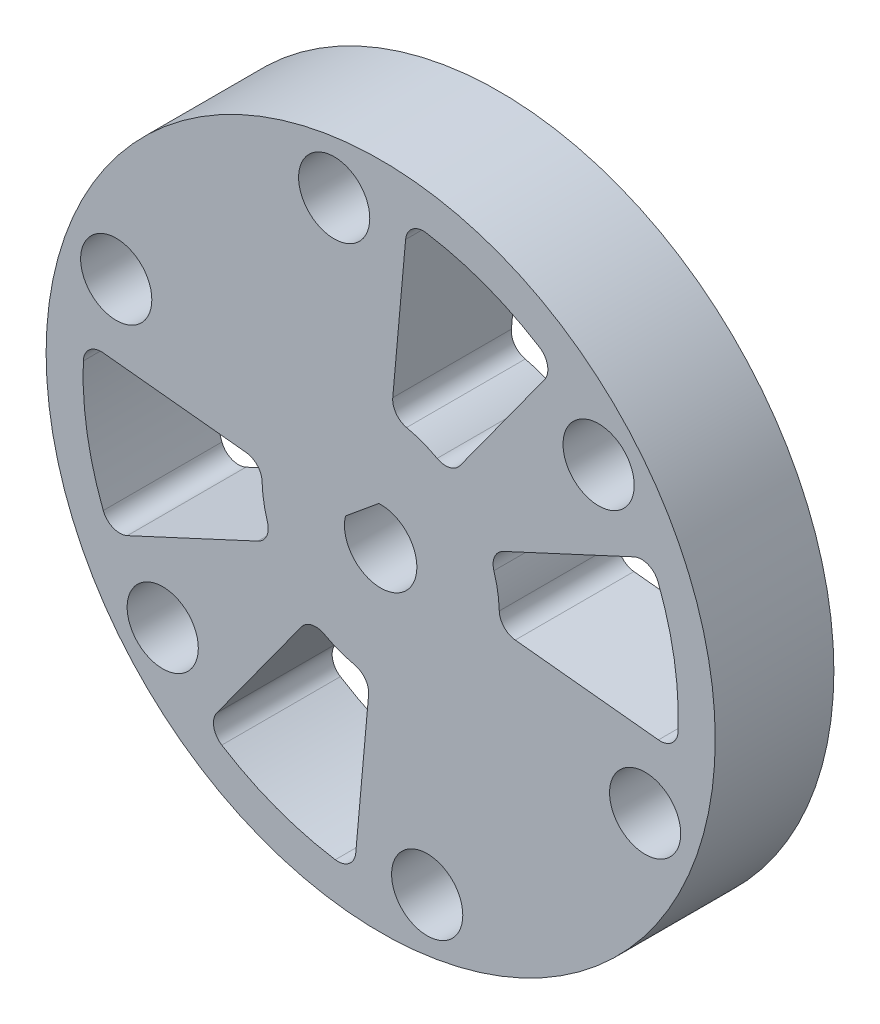
from build123d import *

# Parameters (mm, degrees)
SKETCH1_6_R         = 28.2
SKETCH1_6_R_2       = 3
BOSS_EXTRUDE4_DEPTH = 10
FILLET4_R           = 1.5


with BuildPart() as part:
    # Sketch1_6 → Boss-Extrude4 (new body)
    with BuildSketch(Plane.XY):
        Circle(SKETCH1_6_R)
        with BuildLine():
            ThreePointArc((5.866209712, 8.098616155), (3.505253449, 9.36553246), (0.892648331, 9.960079265))
            Line((0.892648331, 9.960079265), (2.101110424, 23.44397635))
            ThreePointArc((2.101110424, 23.44397635), (2.670485373, 24.491199978), (3.823764506, 24.792550937))
            ThreePointArc((3.823764506, 24.792550937), (8.793169539, 23.494082796), (13.393949598, 21.210701807))
            ThreePointArc((13.393949598, 21.210701807), (14.065968099, 20.226193659), (13.807850128, 19.062475363))
            Line((13.807850128, 19.062475363), (5.866209712, 8.098616155))
        make_face(mode=Mode.SUBTRACT)
        with BuildLine():
            ThreePointArc((-9.946712181, 1.030978557), (-9.863415755, -1.647127697), (-9.072005832, -4.206983501))
            Line((-9.072005832, -4.206983501), (-21.353634297, -9.902373172))
            ThreePointArc((-21.353634297, -9.902373172), (-22.545244036, -9.932891816), (-23.382861189, -9.084798269))
            ThreePointArc((-23.382861189, -9.084798269), (-24.74305731, -4.131933198), (-25.065981396, 0.994149706))
            ThreePointArc((-25.065981396, 0.994149706), (-24.54938158, 2.068388873), (-23.412512987, 2.426711301))
            Line((-23.412512987, 2.426711301), (-9.946712181, 1.030978557))
        make_face(mode=Mode.SUBTRACT)
        with BuildLine():
            ThreePointArc((-5.866209712, -8.098616155), (-3.505253449, -9.36553246), (-0.892648331, -9.960079265))
            Line((-0.892648331, -9.960079265), (-2.101110424, -23.44397635))
            ThreePointArc((-2.101110424, -23.44397635), (-2.670485373, -24.491199978), (-3.823764506, -24.792550937))
            ThreePointArc((-3.823764506, -24.792550937), (-8.793169539, -23.494082796), (-13.393949598, -21.210701807))
            ThreePointArc((-13.393949598, -21.210701807), (-14.065968099, -20.226193659), (-13.807850128, -19.062475363))
            Line((-13.807850128, -19.062475363), (-5.866209712, -8.098616155))
        make_face(mode=Mode.SUBTRACT)
        with BuildLine():
            ThreePointArc((9.946712181, -1.030978557), (9.863415755, 1.647127697), (9.072005832, 4.206983501))
            Line((9.072005832, 4.206983501), (21.353634297, 9.902373172))
            ThreePointArc((21.353634297, 9.902373172), (22.545244036, 9.932891816), (23.382861189, 9.084798269))
            ThreePointArc((23.382861189, 9.084798269), (24.74305731, 4.131933198), (25.065981396, -0.994149706))
            ThreePointArc((25.065981396, -0.994149706), (24.54938158, -2.068388873), (23.412512987, -2.426711301))
            Line((23.412512987, -2.426711301), (9.946712181, -1.030978557))
        make_face(mode=Mode.SUBTRACT)
        with Locations((-18.369803336, -15.132426289)):
            Circle(SKETCH1_6_R_2, mode=Mode.SUBTRACT)
        with Locations((3.920163919, -23.474929496)):
            Circle(SKETCH1_6_R_2, mode=Mode.SUBTRACT)
        with Locations((22.289967255, -8.342503208)):
            Circle(SKETCH1_6_R_2, mode=Mode.SUBTRACT)
        with Locations((-22.289967255, 8.342503208)):
            Circle(SKETCH1_6_R_2, mode=Mode.SUBTRACT)
        with Locations((18.369803336, 15.132426289)):
            Circle(SKETCH1_6_R_2, mode=Mode.SUBTRACT)
        with Locations((-3.920163919, 23.474929496)):
            Circle(SKETCH1_6_R_2, mode=Mode.SUBTRACT)
        with BuildLine():
            ThreePointArc((-0.15563191, 3.046026708), (1.939239503, -2.354113453), (-2.95986762, 0.735991626))
            Line((-2.95986762, 0.735991626), (-0.15563191, 3.046026708))
        make_face(mode=Mode.SUBTRACT)
    extrude(amount=-BOSS_EXTRUDE4_DEPTH)

    # Fillet4
    fillet4_edges = [part.edges().sort_by_distance(p)[0] for p in [
        (-5.866209712, -8.098616155, -5),
        (-0.892648331, -9.960079265, -5),
        (9.072005832, 4.206983501, -5),
        (9.946712181, -1.030978557, -5),
        (0.892648331, 9.960079265, -5),
        (5.866209712, 8.098616155, -5),
        (-9.072005832, -4.206983501, -5),
        (-9.946712181, 1.030978557, -5),
    ]]
    fillet(fillet4_edges, radius=FILLET4_R)


solid = part.part
